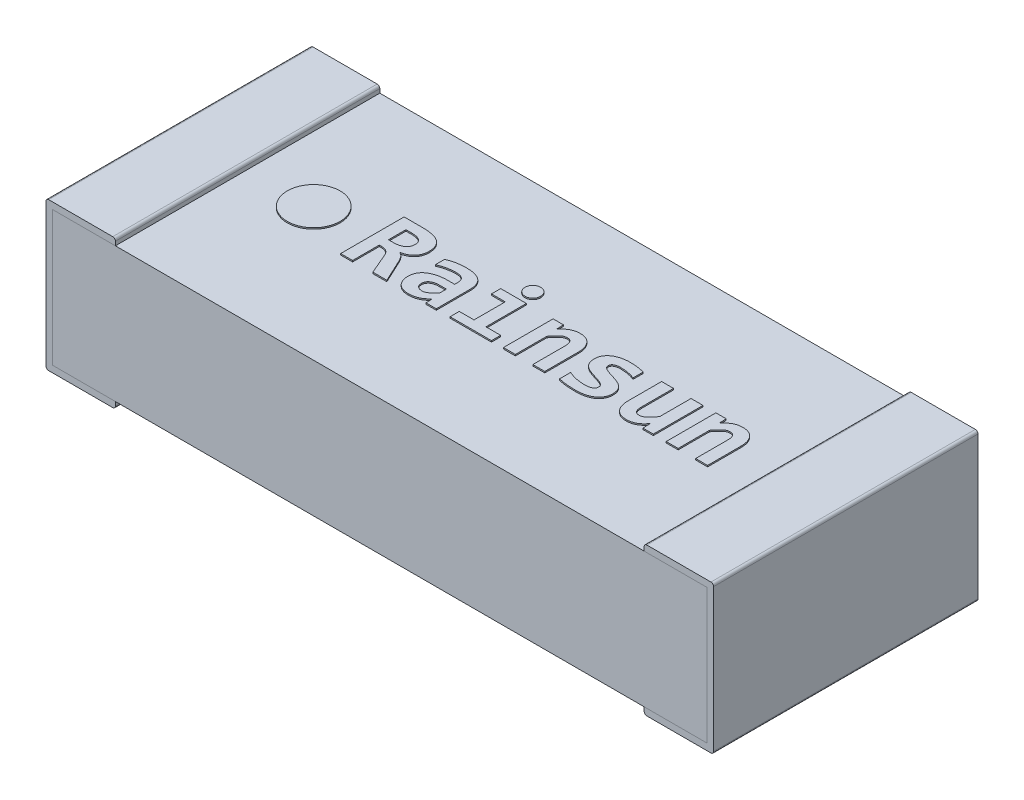
from build123d import *

# Parameters (mm, degrees)
EXTRUDE_THIN1_DEPTH      = 1
EXTRUDE_THIN1_DEPTH_BACK = 1
BOSS_EXTRUDE1_DEPTH      = 1
BOSS_EXTRUDE1_DEPTH_BACK = 1
SKETCH2_W                = 4.95
SKETCH2_H                = 1.02
SKETCH3_R                = 0.2
BOSS_EXTRUDE2_DEPTH      = 0.01
BOSS_EXTRUDE2_2_DEPTH    = 0.01
BOSS_EXTRUDE2_3_DEPTH    = 0.01
BOSS_EXTRUDE2_4_DEPTH    = 0.01
BOSS_EXTRUDE2_5_DEPTH    = 0.01
BOSS_EXTRUDE2_6_DEPTH    = 0.01
BOSS_EXTRUDE2_7_DEPTH    = 0.01
BOSS_EXTRUDE2_8_DEPTH    = 0.01
BOSS_EXTRUDE2_9_DEPTH    = 0.01
FILLET1_R                = 0.02
FILLET2_R                = 0.02


with BuildPart() as part:
    # Sketch1 → Extrude-Thin1 (new, two sides: drawn at the far end of the back side and taken through both)
    with BuildSketch(Plane.XY.offset(-EXTRUDE_THIN1_DEPTH_BACK)):
        Polygon((2, 1.07), (2.475, 1.07), (2.475, 0.05), (2, 0.05), (2, 0), (2.525, 0), (2.525, 1.12), (2, 1.12), align=None)
    extrude(amount=EXTRUDE_THIN1_DEPTH + EXTRUDE_THIN1_DEPTH_BACK)


with BuildPart() as body_2:
    # Mirror1: mirrored copy
    add(part.part.mirror(Plane(origin=(0, 0, 0), x_dir=(0, 0, 1), z_dir=(1, 0, 0))))

    # Fillet2
    fillet2_edges = [body_2.edges().sort_by_distance(p)[0] for p in [
        (-2.525, 0, 0),
        (-2.525, 1.12, 0),
        (-2, 1.12, 0),
        (-2, 0, 0),
    ]]
    fillet(fillet2_edges, radius=FILLET2_R)


with BuildPart() as body_3:
    # Sketch2 → Boss-Extrude1 (new, two sides: drawn at the far end of the back side and taken through both)
    with BuildSketch(Plane.XY.offset(-BOSS_EXTRUDE1_DEPTH_BACK)):
        with Locations((0, 0.56)):
            Rectangle(SKETCH2_W, SKETCH2_H)
    extrude(amount=BOSS_EXTRUDE1_DEPTH + BOSS_EXTRUDE1_DEPTH_BACK)


with BuildPart() as body_4:
    # Sketch3 → Boss-Extrude2 (new body)
    with BuildSketch(Plane(origin=(0, 1.07, 0), x_dir=(1, 0, 0), z_dir=(0, 1, 0))):
        with Locations((-1.5, 0)):
            Circle(SKETCH3_R)
    extrude(amount=BOSS_EXTRUDE2_DEPTH)


with BuildPart() as body_5:
    # Sketch3 → Boss-Extrude2 2 (new body)
    with BuildSketch(Plane(origin=(0, 1.07, 0), x_dir=(1, 0, 0), z_dir=(0, 1, 0))):
        with BuildLine():
            Line((-0.844027182, -0.208611629), (-0.9110924, -0.051981194))
            add(Edge.make_bspline(
                [(-0.9110924, -0.051981194), (-0.912724491, -0.048408124), (-0.915895955, -0.041464965), (-0.92231498, -0.032270437), (-0.929638163, -0.024414484), (-0.93802681, -0.018068753), (-0.947210117, -0.013026992), (-0.957241109, -0.009375934), (-0.968076466, -0.007349202), (-0.975540883, -0.007033659), (-0.979353269, -0.006872498)],
                knots=[0, 0, 0, 0, 1.07937985, 2.097441539, 3.071055259, 4.024539089, 4.97969058, 5.945096662, 6.95047571, 8, 8, 8, 8], degree=3))
            Line((-0.979353269, -0.006872498), (-0.997070661, -0.006872498))
            Line((-0.997070661, -0.006872498), (-0.997070661, -0.208611629))
            Line((-0.997070661, -0.208611629), (-1.087505443, -0.208611629))
            Line((-1.087505443, -0.208611629), (-1.087505443, 0.271388371))
            Line((-1.087505443, 0.271388371), (-0.945114139, 0.271388371))
            add(Edge.make_bspline(
                [(-0.945114139, 0.271388371), (-0.938518721, 0.271294928), (-0.925642888, 0.271112504), (-0.9068017, 0.269982968), (-0.888965799, 0.267748367), (-0.872061074, 0.264897347), (-0.856193594, 0.261028587), (-0.841444195, 0.256092954), (-0.827984555, 0.249846241), (-0.815734388, 0.242538225), (-0.804646038, 0.234194727), (-0.794990984, 0.224505948), (-0.786678676, 0.213647111), (-0.779626238, 0.20160794), (-0.77419529, 0.188202493), (-0.770298097, 0.173453594), (-0.7678709, 0.157301885), (-0.767630237, 0.14603506), (-0.767505443, 0.140192719)],
                knots=[0, 0, 0, 0, 1.254438722, 2.448964256, 3.587437174, 4.671603447, 5.707801299, 6.690588177, 7.624750448, 8.524079809, 9.399245701, 10.256818247, 11.116851234, 11.993805779, 12.902354155, 13.858471343, 14.889524007, 16, 16, 16, 16], degree=3))
            add(Edge.make_bspline(
                [(-0.767505443, 0.140192719), (-0.767613783, 0.135949168), (-0.767824709, 0.127687438), (-0.769350061, 0.115631855), (-0.771951115, 0.104310927), (-0.775549557, 0.093723388), (-0.780040459, 0.083862529), (-0.785353529, 0.074692195), (-0.791617186, 0.066261104), (-0.79867143, 0.05856408), (-0.806446125, 0.051615672), (-0.814759336, 0.04522194), (-0.823760456, 0.039600937), (-0.833362472, 0.034747762), (-0.843360775, 0.030458428), (-0.853821712, 0.027041425), (-0.864627966, 0.024148858), (-0.872023009, 0.022821259), (-0.875766313, 0.022149241)],
                knots=[0, 0, 0, 0, 1.155349972, 2.249340124, 3.302347646, 4.313193118, 5.288908417, 6.248327119, 7.193487508, 8.143168254, 9.086215168, 10.029416886, 10.995709606, 11.970826185, 12.956664107, 13.955010984, 14.964844911, 16, 16, 16, 16], degree=3))
            add(Edge.make_bspline(
                [(-0.875766313, 0.022149241), (-0.872863792, 0.021388251), (-0.866958302, 0.019839936), (-0.858648882, 0.015387682), (-0.850657058, 0.009596146), (-0.843055631, 0.002125517), (-0.835746063, -0.007110378), (-0.828388906, -0.018075842), (-0.821129166, -0.03097671), (-0.816618277, -0.040323584), (-0.814244574, -0.045242063)],
                knots=[0, 0, 0, 0, 0.75991202, 1.546122521, 2.376404305, 3.261596413, 4.243343524, 5.3639781, 6.612881775, 8, 8, 8, 8], degree=3))
            Line((-0.814244574, -0.045242063), (-0.738048922, -0.208611629))
            Line((-0.738048922, -0.208611629), (-0.844027182, -0.208611629))
        make_face()
        with BuildLine():
            add(Edge.make_bspline(
                [(-0.864896748, 0.130410111), (-0.864948738, 0.13316709), (-0.865049739, 0.138523065), (-0.866130627, 0.146259122), (-0.868010843, 0.153388059), (-0.870455141, 0.159912803), (-0.873688298, 0.165857964), (-0.877706405, 0.17114269), (-0.882413792, 0.175875867), (-0.887873959, 0.179931668), (-0.893952459, 0.18351969), (-0.900789425, 0.186551317), (-0.908302451, 0.189183712), (-0.916580804, 0.191179279), (-0.92554313, 0.192823986), (-0.935235431, 0.193982811), (-0.945644261, 0.19478164), (-0.952829902, 0.194837758), (-0.956527182, 0.194866632)],
                knots=[0, 0, 0, 0, 1.03221539, 2.00528173, 2.91708139, 3.789130794, 4.609038712, 5.442315575, 6.267597059, 7.100873922, 7.98300273, 8.906244241, 9.897686097, 10.9608414, 12.092146654, 13.309174969, 14.615470257, 16, 16, 16, 16], degree=3))
            Line((-0.956527182, 0.194866632), (-0.997070661, 0.194866632))
            Line((-0.997070661, 0.194866632), (-0.997070661, 0.062692719))
            Line((-0.997070661, 0.062692719), (-0.959570661, 0.062692719))
            add(Edge.make_bspline(
                [(-0.959570661, 0.062692719), (-0.952745168, 0.062887139), (-0.939667367, 0.063259652), (-0.923838839, 0.065980449), (-0.912285862, 0.069103671), (-0.904529893, 0.072254502), (-0.89730981, 0.075665841), (-0.89075745, 0.079719428), (-0.884837111, 0.08425857), (-0.879730044, 0.089438511), (-0.875193687, 0.094987795), (-0.871474424, 0.101138485), (-0.868564006, 0.107798969), (-0.86632236, 0.114887197), (-0.865164977, 0.122509959), (-0.864987894, 0.127725569), (-0.864896748, 0.130410111)],
                knots=[0, 0, 0, 0, 2.184691281, 4.185918933, 5.126368008, 6.012027286, 6.863184627, 7.681184451, 8.47504028, 9.246354907, 10.005704987, 10.765941227, 11.540044168, 12.329221459, 13.140028664, 14, 14, 14, 14], degree=3))
        make_face(mode=Mode.SUBTRACT)
    extrude(amount=BOSS_EXTRUDE2_2_DEPTH)


with BuildPart() as body_6:
    # Sketch3 → Boss-Extrude2 3 (new body)
    with BuildSketch(Plane(origin=(0, 1.07, 0), x_dir=(1, 0, 0), z_dir=(0, 1, 0))):
        with BuildLine():
            Line((-0.441635878, -0.208611629), (-0.443809791, -0.159155107))
            add(Edge.make_bspline(
                [(-0.443809791, -0.159155107), (-0.447709917, -0.163119123), (-0.455483575, -0.171020125), (-0.467992706, -0.181934175), (-0.481439504, -0.191776329), (-0.496161515, -0.200059481), (-0.512260222, -0.206717955), (-0.52966785, -0.211901404), (-0.548740743, -0.214951572), (-0.561950829, -0.215357423), (-0.568809791, -0.21556815)],
                knots=[0, 0, 0, 0, 0.942751787, 1.87907519, 2.811864331, 3.763701556, 4.73586472, 5.760432521, 6.837168281, 8, 8, 8, 8], degree=3))
            add(Edge.make_bspline(
                [(-0.568809791, -0.21556815), (-0.57337887, -0.215457971), (-0.582289532, -0.215243099), (-0.595215477, -0.213749186), (-0.607306842, -0.21113623), (-0.618527609, -0.207448713), (-0.6288465, -0.2027656), (-0.638329708, -0.197284177), (-0.646917861, -0.19096641), (-0.65473705, -0.183871567), (-0.661536368, -0.175886197), (-0.667651633, -0.167261824), (-0.67257331, -0.157688149), (-0.676883017, -0.147476364), (-0.680080344, -0.136524097), (-0.682348717, -0.12499052), (-0.683814347, -0.112961039), (-0.68395555, -0.104739117), (-0.684027182, -0.10056815)],
                knots=[0, 0, 0, 0, 1.188820374, 2.318449472, 3.379888704, 4.402475042, 5.385577281, 6.32342832, 7.24738733, 8.154894716, 9.063967784, 9.97147517, 10.899274027, 11.85872107, 12.852031674, 13.861540196, 14.915163189, 16, 16, 16, 16], degree=3))
            add(Edge.make_bspline(
                [(-0.684027182, -0.10056815), (-0.683929602, -0.096245089), (-0.683737233, -0.087722692), (-0.681381268, -0.075286898), (-0.678096956, -0.063270458), (-0.673159253, -0.051845821), (-0.666794841, -0.04101833), (-0.65910857, -0.030857148), (-0.649765661, -0.021651163), (-0.63911547, -0.013155708), (-0.626924375, -0.005571348), (-0.61345668, 0.001290715), (-0.598517369, 0.007153849), (-0.582200877, 0.012119147), (-0.564416532, 0.016185085), (-0.545144837, 0.018894166), (-0.524424157, 0.02070483), (-0.510118352, 0.020868815), (-0.502722835, 0.020953589)],
                knots=[0, 0, 0, 0, 0.846334836, 1.668447797, 2.473381772, 3.284808262, 4.099802161, 4.930887555, 5.774685007, 6.664352488, 7.596475241, 8.584410062, 9.623785724, 10.738215398, 11.925463769, 13.196192477, 14.550545786, 16, 16, 16, 16], degree=3))
            Line((-0.502722835, 0.020953589), (-0.454461965, 0.020953589))
            Line((-0.454461965, 0.020953589), (-0.454461965, 0.043018806))
            add(Edge.make_bspline(
                [(-0.454461965, 0.043018806), (-0.454626751, 0.04749412), (-0.454944495, 0.056123539), (-0.458024842, 0.068375239), (-0.463230273, 0.079271331), (-0.46982471, 0.086768163), (-0.476246413, 0.09163378), (-0.481679373, 0.095079269), (-0.487909063, 0.09781367), (-0.49472936, 0.100239178), (-0.502274599, 0.102250114), (-0.51066674, 0.103422541), (-0.519838328, 0.104391165), (-0.526234194, 0.104417902), (-0.529570661, 0.10443185)],
                knots=[0, 0, 0, 0, 1.447721202, 2.79153421, 4.061974913, 5.326381525, 5.97912129, 6.669712629, 7.405140625, 8.177401359, 9.014479125, 9.929270305, 10.919783635, 12, 12, 12, 12], degree=3))
            add(Edge.make_bspline(
                [(-0.529570661, 0.10443185), (-0.535008804, 0.104357696), (-0.545903537, 0.104209138), (-0.562155131, 0.102710789), (-0.578353121, 0.100473913), (-0.599654915, 0.096042767), (-0.626005571, 0.089001452), (-0.646133255, 0.080738753), (-0.656201095, 0.076605763)],
                knots=[0, 0, 0, 0, 0.749590158, 1.5017228, 2.248461115, 3.002830009, 4.500819683, 6, 6, 6, 6], degree=3))
            Line((-0.656201095, 0.076605763), (-0.656201095, 0.14617098))
            add(Edge.make_bspline(
                [(-0.656201095, 0.14617098), (-0.651585603, 0.148148122), (-0.642133848, 0.152196976), (-0.627139904, 0.157333599), (-0.611214265, 0.162162376), (-0.594289086, 0.166214642), (-0.576722777, 0.169725424), (-0.558652573, 0.172238357), (-0.540244903, 0.173630614), (-0.527869964, 0.173874304), (-0.521635878, 0.173997067)],
                knots=[0, 0, 0, 0, 0.870643359, 1.78293153, 2.747244943, 3.756289436, 4.800212086, 5.853400504, 6.918614031, 8, 8, 8, 8], degree=3))
            add(Edge.make_bspline(
                [(-0.521635878, 0.173997067), (-0.514967081, 0.173879689), (-0.502121187, 0.173653587), (-0.483560782, 0.172298581), (-0.466488551, 0.169820773), (-0.450820732, 0.166352106), (-0.43654095, 0.16194037), (-0.423550941, 0.156488243), (-0.411923425, 0.149988597), (-0.401555581, 0.142517831), (-0.392461157, 0.134120628), (-0.384628485, 0.124678772), (-0.378221666, 0.114129335), (-0.372969312, 0.102635716), (-0.368987227, 0.090140704), (-0.36603811, 0.076684523), (-0.364299576, 0.062231233), (-0.364119536, 0.052262705), (-0.364027182, 0.047149241)],
                knots=[0, 0, 0, 0, 1.377759711, 2.653935252, 3.841633143, 4.938469235, 5.965914915, 6.92517161, 7.843396777, 8.711792949, 9.559226208, 10.39396998, 11.237393933, 12.101553923, 12.998669062, 13.941252007, 14.943942973, 16, 16, 16, 16], degree=3))
            Line((-0.364027182, 0.047149241), (-0.364027182, -0.208611629))
            Line((-0.364027182, -0.208611629), (-0.441635878, -0.208611629))
        make_face()
        with BuildLine():
            Line((-0.454461965, -0.041655107), (-0.506853269, -0.041655107))
            add(Edge.make_bspline(
                [(-0.506853269, -0.041655107), (-0.510331638, -0.041739255), (-0.517043124, -0.04190162), (-0.526729811, -0.042531769), (-0.535568555, -0.044146716), (-0.543608134, -0.046048084), (-0.550905862, -0.048435928), (-0.557389618, -0.051382079), (-0.563243656, -0.05464593), (-0.569939281, -0.059461878), (-0.576769101, -0.066589127), (-0.582666466, -0.076396134), (-0.586025409, -0.08723894), (-0.586430458, -0.094712639), (-0.586635878, -0.098502933)],
                knots=[0, 0, 0, 0, 1.1346769, 2.18935077, 3.160455313, 4.060166297, 4.882052532, 5.659342063, 6.378819937, 7.064121245, 8.342468752, 9.566207994, 10.765699828, 12, 12, 12, 12], degree=3))
            add(Edge.make_bspline(
                [(-0.586635878, -0.098502933), (-0.586483805, -0.102141754), (-0.586193463, -0.109089121), (-0.583594423, -0.118889623), (-0.579036312, -0.127240371), (-0.57278458, -0.134178096), (-0.564949069, -0.139482397), (-0.555831879, -0.143330989), (-0.545443195, -0.145623723), (-0.538097296, -0.145872471), (-0.534244574, -0.146002933)],
                knots=[0, 0, 0, 0, 1.086697673, 2.074761695, 3.000659932, 3.905665256, 4.840141479, 5.805924735, 6.849267962, 8, 8, 8, 8], degree=3))
            add(Edge.make_bspline(
                [(-0.534244574, -0.146002933), (-0.531218551, -0.145829094), (-0.524987283, -0.145471122), (-0.515667567, -0.14261902), (-0.506100472, -0.138395598), (-0.496524759, -0.132103229), (-0.486667196, -0.12427944), (-0.476207271, -0.115149988), (-0.465337373, -0.104464507), (-0.45819142, -0.096619146), (-0.454461965, -0.092524672)],
                knots=[0, 0, 0, 0, 0.735319699, 1.514190145, 2.354950119, 3.274773688, 4.292602642, 5.417493931, 6.652196731, 8, 8, 8, 8], degree=3))
            Line((-0.454461965, -0.092524672), (-0.454461965, -0.041655107))
        make_face(mode=Mode.SUBTRACT)
    extrude(amount=BOSS_EXTRUDE2_3_DEPTH)


with BuildPart() as body_7:
    # Sketch3 → Boss-Extrude2 4 (new body)
    with BuildSketch(Plane(origin=(0, 1.07, 0), x_dir=(1, 0, 0), z_dir=(0, 1, 0))):
        with BuildLine():
            add(Edge.make_bspline(
                [(-0.050983704, 0.267692719), (-0.051171373, 0.263715714), (-0.051541823, 0.255865291), (-0.055127323, 0.244677359), (-0.060389838, 0.234467659), (-0.06765613, 0.225732885), (-0.076446194, 0.218526987), (-0.086490256, 0.212975645), (-0.097861985, 0.209455409), (-0.105813413, 0.209008949), (-0.109896748, 0.208779676)],
                knots=[0, 0, 0, 0, 1.027278296, 2.027799504, 3.01435772, 3.987703108, 4.947837318, 5.943283625, 6.943804833, 8, 8, 8, 8], degree=3))
            add(Edge.make_bspline(
                [(-0.109896748, 0.208779676), (-0.113975348, 0.209023347), (-0.12202171, 0.209504068), (-0.133556147, 0.21288676), (-0.143679679, 0.218609168), (-0.152681345, 0.225616256), (-0.159817978, 0.234517424), (-0.165109423, 0.244669374), (-0.168684259, 0.255867361), (-0.169056166, 0.26371641), (-0.169244574, 0.267692719)],
                knots=[0, 0, 0, 0, 1.05151676, 2.074458121, 3.065495108, 4.035879517, 4.99899435, 5.981182615, 6.977272023, 8, 8, 8, 8], degree=3))
            add(Edge.make_bspline(
                [(-0.169244574, 0.267692719), (-0.169059161, 0.271705685), (-0.168694793, 0.279591852), (-0.165111803, 0.290824987), (-0.159796078, 0.301001098), (-0.152647166, 0.309959392), (-0.143786134, 0.317260448), (-0.133493764, 0.322757301), (-0.122049296, 0.326361044), (-0.113981119, 0.326812171), (-0.109896748, 0.327040545)],
                knots=[0, 0, 0, 0, 1.028612134, 2.021399971, 3.000332741, 3.967500779, 4.946433548, 5.929741804, 6.951968527, 8, 8, 8, 8], degree=3))
            add(Edge.make_bspline(
                [(-0.109896748, 0.327040545), (-0.105807412, 0.326826904), (-0.097833575, 0.326410324), (-0.086552849, 0.322669261), (-0.076338645, 0.317341495), (-0.067692994, 0.309842499), (-0.060411331, 0.301050551), (-0.055125009, 0.290817073), (-0.051531248, 0.279593927), (-0.051168363, 0.271706384), (-0.050983704, 0.267692719)],
                knots=[0, 0, 0, 0, 1.052651845, 2.052576496, 3.040219784, 4.00912662, 4.986439932, 5.969688445, 6.966853106, 8, 8, 8, 8], degree=3))
        make_face()
    extrude(amount=BOSS_EXTRUDE2_4_DEPTH)


with BuildPart() as body_8:
    # Sketch3 → Boss-Extrude2 5 (new body)
    with BuildSketch(Plane(origin=(0, 1.07, 0), x_dir=(1, 0, 0), z_dir=(0, 1, 0))):
        Polygon((-0.148375009, 0.097475328), (-0.252722835, 0.097475328), (-0.252722835, 0.167040545), (-0.057940226, 0.167040545), (-0.057940226, -0.139046411), (0.053364122, -0.139046411), (0.053364122, -0.208611629), (-0.259679356, -0.208611629), (-0.259679356, -0.139046411), (-0.148375009, -0.139046411), align=None)
    extrude(amount=BOSS_EXTRUDE2_5_DEPTH)


with BuildPart() as body_9:
    # Sketch3 → Boss-Extrude2 6 (new body)
    with BuildSketch(Plane(origin=(0, 1.07, 0), x_dir=(1, 0, 0), z_dir=(0, 1, 0))):
        with BuildLine():
            Line((0.3664076, -0.208611629), (0.3664076, 0.035844893))
            add(Edge.make_bspline(
                [(0.3664076, 0.035844893), (0.366259792, 0.040670573), (0.365982627, 0.049719553), (0.364012298, 0.062413279), (0.360478821, 0.073161917), (0.3555561, 0.082126802), (0.348954376, 0.089064561), (0.340942465, 0.094100907), (0.331413316, 0.096974791), (0.324652203, 0.097302342), (0.321081513, 0.097475328)],
                knots=[0, 0, 0, 0, 1.330337845, 2.494612452, 3.527515131, 4.435664575, 5.29056087, 6.138661007, 7.016986611, 8, 8, 8, 8], degree=3))
            add(Edge.make_bspline(
                [(0.321081513, 0.097475328), (0.317325831, 0.097226678), (0.309774256, 0.096726714), (0.298578937, 0.093153556), (0.287815749, 0.087144608), (0.277291584, 0.078904816), (0.267022785, 0.068627196), (0.256123049, 0.057015669), (0.245276719, 0.043445325), (0.23801259, 0.033798231), (0.234233687, 0.028779676)],
                knots=[0, 0, 0, 0, 0.785464114, 1.579338109, 2.434441881, 3.353550729, 4.367060634, 5.472426257, 6.685120424, 8, 8, 8, 8], degree=3))
            Line((0.234233687, 0.028779676), (0.234233687, -0.208611629))
            Line((0.234233687, -0.208611629), (0.143798905, -0.208611629))
            Line((0.143798905, -0.208611629), (0.143798905, 0.167040545))
            Line((0.143798905, 0.167040545), (0.22216847, 0.167040545))
            Line((0.22216847, 0.167040545), (0.224342383, 0.111605763))
            add(Edge.make_bspline(
                [(0.224342383, 0.111605763), (0.228164433, 0.116146657), (0.235682864, 0.125079141), (0.247735358, 0.137456067), (0.260592735, 0.148346185), (0.27449802, 0.157477497), (0.289528043, 0.164682378), (0.305741664, 0.170114231), (0.323589883, 0.173465484), (0.336065942, 0.173814295), (0.342603252, 0.173997067)],
                knots=[0, 0, 0, 0, 1.024448882, 2.015214114, 2.978651595, 3.927625391, 4.878802298, 5.848009221, 6.87238172, 8, 8, 8, 8], degree=3))
            add(Edge.make_bspline(
                [(0.342603252, 0.173997067), (0.347248956, 0.17392269), (0.356254236, 0.173778517), (0.369270491, 0.171810559), (0.38140735, 0.168986963), (0.392552423, 0.164763594), (0.402882997, 0.159681927), (0.412222361, 0.15345182), (0.420742284, 0.146290939), (0.428330122, 0.138120655), (0.435055657, 0.129054346), (0.441065397, 0.119183453), (0.445844092, 0.108280855), (0.449889287, 0.096614145), (0.453018276, 0.084172495), (0.455303383, 0.071024588), (0.456601789, 0.057139365), (0.456760869, 0.04765917), (0.456842383, 0.042801415)],
                knots=[0, 0, 0, 0, 1.128292418, 2.187093889, 3.193297493, 4.152042544, 5.077728068, 5.986496946, 6.874059951, 7.777692081, 8.690209529, 9.614679004, 10.580558963, 11.577778426, 12.613878209, 13.695586306, 14.819193276, 16, 16, 16, 16], degree=3))
            Line((0.456842383, 0.042801415), (0.456842383, -0.208611629))
            Line((0.456842383, -0.208611629), (0.3664076, -0.208611629))
        make_face()
    extrude(amount=BOSS_EXTRUDE2_6_DEPTH)


with BuildPart() as body_10:
    # Sketch3 → Boss-Extrude2 7 (new body)
    with BuildSketch(Plane(origin=(0, 1.07, 0), x_dir=(1, 0, 0), z_dir=(0, 1, 0))):
        with BuildLine():
            add(Edge.make_bspline(
                [(0.860320644, -0.097307281), (0.860167168, -0.102464036), (0.859871038, -0.112413943), (0.857204729, -0.126802435), (0.852774731, -0.139981812), (0.846599899, -0.152004559), (0.838910538, -0.162738896), (0.830140968, -0.172529919), (0.820214718, -0.181250677), (0.809147658, -0.188848519), (0.797209725, -0.195479917), (0.784359205, -0.201007617), (0.770812025, -0.205684388), (0.756580405, -0.209314203), (0.741950852, -0.212141202), (0.727026843, -0.214056698), (0.711935709, -0.215296743), (0.701808547, -0.215477547), (0.696733687, -0.21556815)],
                knots=[0, 0, 0, 0, 1.09100478, 2.105082402, 3.085106755, 4.025136879, 4.955223976, 5.873211658, 6.802665871, 7.745321433, 8.710187751, 9.689250942, 10.703270536, 11.74146176, 12.796073428, 13.856028036, 14.925626204, 16, 16, 16, 16], degree=3))
            add(Edge.make_bspline(
                [(0.696733687, -0.21556815), (0.690102935, -0.215524524), (0.677164164, -0.215439394), (0.658275372, -0.214834056), (0.640378615, -0.213572878), (0.618118571, -0.211633897), (0.591702623, -0.2081043), (0.571203697, -0.203771587), (0.561190209, -0.201655107)],
                knots=[0, 0, 0, 0, 0.874092444, 1.705641045, 2.49069391, 3.2387718, 4.651171983, 6, 6, 6, 6], degree=3))
            Line((0.561190209, -0.201655107), (0.561190209, -0.118176846))
            add(Edge.make_bspline(
                [(0.561190209, -0.118176846), (0.566850865, -0.120533303), (0.578056265, -0.125197965), (0.595178901, -0.130835221), (0.612170571, -0.135866556), (0.629149964, -0.139593635), (0.645888069, -0.142380323), (0.662162155, -0.144489216), (0.677982981, -0.145711948), (0.688362193, -0.145906927), (0.693472818, -0.146002933)],
                knots=[0, 0, 0, 0, 1.081001824, 2.139868395, 3.177367493, 4.2052384, 5.203238289, 6.169410181, 7.098635214, 8, 8, 8, 8], degree=3))
            add(Edge.make_bspline(
                [(0.693472818, -0.146002933), (0.698915514, -0.145904263), (0.709157395, -0.145718591), (0.723390069, -0.1436913), (0.735542273, -0.140425092), (0.745447559, -0.135641565), (0.753287009, -0.129783776), (0.758823682, -0.122810206), (0.76233756, -0.114967688), (0.762730811, -0.109371561), (0.762929339, -0.106546411)],
                knots=[0, 0, 0, 0, 1.469547571, 2.76534487, 3.874676932, 4.855352958, 5.720794042, 6.494385122, 7.239905003, 8, 8, 8, 8], degree=3))
            add(Edge.make_bspline(
                [(0.762929339, -0.106546411), (0.762791428, -0.103801666), (0.76252211, -0.098441636), (0.759434899, -0.090680639), (0.753854483, -0.083466166), (0.746886769, -0.078372398), (0.739890695, -0.074275253), (0.733341614, -0.071031771), (0.725775945, -0.067785922), (0.717155108, -0.064394182), (0.707258938, -0.060950859), (0.696103576, -0.057092362), (0.683463072, -0.053232254), (0.674562557, -0.050630743), (0.669885861, -0.049263802)],
                knots=[0, 0, 0, 0, 0.84533218, 1.65079333, 2.538454206, 3.632493948, 4.295634353, 5.047457499, 5.890706844, 6.841828332, 7.912366296, 9.131567036, 10.492807614, 12, 12, 12, 12], degree=3))
            add(Edge.make_bspline(
                [(0.669885861, -0.049263802), (0.665453528, -0.04796115), (0.656865135, -0.045437041), (0.644491514, -0.041116743), (0.632932321, -0.036735718), (0.622179847, -0.032083516), (0.612346669, -0.026942819), (0.603360881, -0.021445065), (0.595187462, -0.015558587), (0.588018334, -0.009109196), (0.581585258, -0.002231402), (0.576221417, 0.005281143), (0.571548653, 0.013226537), (0.567730642, 0.0217445), (0.564771508, 0.030965839), (0.562783845, 0.040887171), (0.561403599, 0.051531233), (0.561263034, 0.058883569), (0.561190209, 0.062692719)],
                knots=[0, 0, 0, 0, 1.298059187, 2.515208454, 3.681910853, 4.771561692, 5.80536043, 6.797244313, 7.72998402, 8.631353089, 9.503256889, 10.370869679, 11.219576383, 12.090052196, 12.98842591, 13.934956945, 14.930127727, 16, 16, 16, 16], degree=3))
            add(Edge.make_bspline(
                [(0.561190209, 0.062692719), (0.561313322, 0.066433511), (0.561558852, 0.073893949), (0.563603651, 0.084866537), (0.566749557, 0.095531338), (0.57123199, 0.105797234), (0.577042533, 0.115576981), (0.583973018, 0.124900491), (0.592391148, 0.133375133), (0.601877918, 0.14137104), (0.612647909, 0.148644901), (0.624728009, 0.155063993), (0.638002391, 0.16069459), (0.652532219, 0.165501121), (0.668355406, 0.169254924), (0.685415769, 0.172095643), (0.703767948, 0.173702226), (0.716404502, 0.173896668), (0.722929339, 0.173997067)],
                knots=[0, 0, 0, 0, 0.81844251, 1.632258835, 2.435372986, 3.248879964, 4.077409159, 4.921438882, 5.785327376, 6.686227262, 7.634496058, 8.624673457, 9.676692434, 10.787963939, 11.971224401, 13.233604305, 14.571581922, 16, 16, 16, 16], degree=3))
            add(Edge.make_bspline(
                [(0.722929339, 0.173997067), (0.72858322, 0.173979533), (0.739608428, 0.17394534), (0.755589231, 0.172985808), (0.770620783, 0.171798305), (0.788747417, 0.169125818), (0.809385953, 0.165507403), (0.825189295, 0.161815866), (0.832603252, 0.160084024)],
                knots=[0, 0, 0, 0, 0.917866331, 1.789862171, 2.598956885, 3.365252049, 4.763938053, 6, 6, 6, 6], degree=3))
            Line((0.832603252, 0.160084024), (0.832603252, 0.083562285))
            add(Edge.make_bspline(
                [(0.832603252, 0.083562285), (0.827436964, 0.085382785), (0.817350475, 0.088937069), (0.802297847, 0.093395852), (0.787723103, 0.097028274), (0.769007697, 0.100548257), (0.746077925, 0.103737423), (0.727760233, 0.104201876), (0.718690209, 0.10443185)],
                knots=[0, 0, 0, 0, 0.846930216, 1.653518287, 2.426723928, 3.168432911, 4.597946698, 6, 6, 6, 6], degree=3))
            add(Edge.make_bspline(
                [(0.718690209, 0.10443185), (0.714371089, 0.104352165), (0.706164536, 0.104200759), (0.69450327, 0.102406107), (0.684130341, 0.099671538), (0.675191503, 0.09581062), (0.667790752, 0.091007793), (0.66254497, 0.084960442), (0.659024461, 0.078034428), (0.658731309, 0.072988492), (0.658581513, 0.070410111)],
                knots=[0, 0, 0, 0, 1.353575655, 2.571864774, 3.691201644, 4.708948433, 5.616762544, 6.430341097, 7.197932669, 8, 8, 8, 8], degree=3))
            add(Edge.make_bspline(
                [(0.658581513, 0.070410111), (0.658760024, 0.06771684), (0.659103113, 0.062540497), (0.661498079, 0.054882986), (0.667020503, 0.048132456), (0.673450764, 0.043055884), (0.680185439, 0.039138773), (0.686473577, 0.036011539), (0.693602034, 0.032601487), (0.70183175, 0.029275745), (0.711186467, 0.025701927), (0.721900312, 0.022248199), (0.733921852, 0.018335187), (0.742448934, 0.01592289), (0.746951078, 0.014649241)],
                knots=[0, 0, 0, 0, 0.870697754, 1.673441418, 2.541463244, 3.639458581, 4.305527314, 5.053652362, 5.906646156, 6.855989708, 7.918451188, 9.139200481, 10.489549865, 12, 12, 12, 12], degree=3))
            add(Edge.make_bspline(
                [(0.746951078, 0.014649241), (0.752073597, 0.013135058), (0.761943772, 0.010217497), (0.775960534, 0.005305015), (0.788716744, 0.000289876), (0.800327278, -0.00474492), (0.810666766, -0.010238874), (0.820067003, -0.015861403), (0.828258372, -0.022026236), (0.835462335, -0.02854037), (0.841704306, -0.035384603), (0.846965874, -0.042711946), (0.851260213, -0.050527939), (0.85459364, -0.058834872), (0.857250995, -0.067632294), (0.85905501, -0.076992288), (0.860174025, -0.086953689), (0.86027083, -0.093789648), (0.860320644, -0.097307281)],
                knots=[0, 0, 0, 0, 1.468847332, 2.830205578, 4.082896833, 5.238283093, 6.307996066, 7.300882441, 8.247490943, 9.122195316, 9.968750424, 10.790004622, 11.59717443, 12.415036503, 13.247279274, 14.120790984, 15.033000747, 16, 16, 16, 16], degree=3))
        make_face()
    extrude(amount=BOSS_EXTRUDE2_7_DEPTH)


with BuildPart() as body_11:
    # Sketch3 → Boss-Extrude2 8 (new body)
    with BuildSketch(Plane(origin=(0, 1.07, 0), x_dir=(1, 0, 0), z_dir=(0, 1, 0))):
        with BuildLine():
            Line((1.055103252, 0.167040545), (1.055103252, -0.077089889))
            add(Edge.make_bspline(
                [(1.055103252, -0.077089889), (1.055253916, -0.081878681), (1.055537433, -0.090890152), (1.057487282, -0.103554837), (1.061087211, -0.114341919), (1.065919835, -0.123449418), (1.072521302, -0.130530635), (1.080646207, -0.135583948), (1.090265788, -0.138561997), (1.097146714, -0.13887976), (1.100755426, -0.139046411)],
                knots=[0, 0, 0, 0, 1.31270137, 2.470220042, 3.497129097, 4.417319378, 5.2744763, 6.117655166, 7.012801186, 8, 8, 8, 8], degree=3))
            add(Edge.make_bspline(
                [(1.100755426, -0.139046411), (1.104480109, -0.138810983), (1.111982184, -0.138336794), (1.122985432, -0.134551248), (1.133774964, -0.128761447), (1.144067793, -0.120299664), (1.154467247, -0.110070414), (1.165277685, -0.098303021), (1.176278555, -0.084800391), (1.183507705, -0.075160071), (1.187277165, -0.070133368)],
                knots=[0, 0, 0, 0, 0.779254789, 1.569537317, 2.415803147, 3.33516661, 4.350409456, 5.47398431, 6.682872188, 8, 8, 8, 8], degree=3))
            Line((1.187277165, -0.070133368), (1.187277165, 0.167040545))
            Line((1.187277165, 0.167040545), (1.277711948, 0.167040545))
            Line((1.277711948, 0.167040545), (1.277711948, -0.208611629))
            Line((1.277711948, -0.208611629), (1.199342383, -0.208611629))
            Line((1.199342383, -0.208611629), (1.19716847, -0.153176846))
            add(Edge.make_bspline(
                [(1.19716847, -0.153176846), (1.193258646, -0.157668136), (1.185580523, -0.166488142), (1.173618571, -0.17886654), (1.160888734, -0.189687053), (1.147220039, -0.198864367), (1.132231725, -0.206057173), (1.115993056, -0.211572214), (1.098147285, -0.215045905), (1.085699505, -0.215389615), (1.079233687, -0.21556815)],
                knots=[0, 0, 0, 0, 1.030992754, 2.024666126, 2.977293315, 3.918575094, 4.866896227, 5.846891158, 6.88159887, 8, 8, 8, 8], degree=3))
            add(Edge.make_bspline(
                [(1.079233687, -0.21556815), (1.074623948, -0.215493026), (1.065618465, -0.215346266), (1.052616641, -0.213360655), (1.040387359, -0.210672351), (1.029152197, -0.206457373), (1.018782349, -0.20126726), (1.009343132, -0.194966416), (1.000707357, -0.187819952), (0.993073088, -0.179609385), (0.986396252, -0.170450341), (0.980533145, -0.160490289), (0.97562772, -0.149616133), (0.971640403, -0.137962521), (0.96844584, -0.125540227), (0.966392666, -0.11235802), (0.964859356, -0.098502336), (0.964733127, -0.089014803), (0.96466847, -0.084155107)],
                knots=[0, 0, 0, 0, 1.116811866, 2.181778732, 3.18353378, 4.148223296, 5.083490636, 5.990084579, 6.894632225, 7.796101715, 8.701204023, 9.638574155, 10.594136258, 11.5889691, 12.622589212, 13.700240707, 14.822019272, 16, 16, 16, 16], degree=3))
            Line((0.96466847, -0.084155107), (0.96466847, 0.167040545))
            Line((0.96466847, 0.167040545), (1.055103252, 0.167040545))
        make_face()
    extrude(amount=BOSS_EXTRUDE2_8_DEPTH)


with BuildPart() as body_12:
    # Sketch3 → Boss-Extrude2 9 (new body)
    with BuildSketch(Plane(origin=(0, 1.07, 0), x_dir=(1, 0, 0), z_dir=(0, 1, 0))):
        with BuildLine():
            Line((1.597711948, -0.208611629), (1.597711948, 0.035844893))
            add(Edge.make_bspline(
                [(1.597711948, 0.035844893), (1.59756414, 0.040670573), (1.597286975, 0.049719553), (1.595316646, 0.062413279), (1.591783169, 0.073161917), (1.586860448, 0.082126802), (1.580258724, 0.089064561), (1.572246813, 0.094100907), (1.562717664, 0.096974791), (1.555956551, 0.097302342), (1.552385861, 0.097475328)],
                knots=[0, 0, 0, 0, 1.330337845, 2.494612452, 3.527515131, 4.435664575, 5.29056087, 6.138661007, 7.016986611, 8, 8, 8, 8], degree=3))
            add(Edge.make_bspline(
                [(1.552385861, 0.097475328), (1.548630179, 0.097226678), (1.541078603, 0.096726714), (1.529883285, 0.093153556), (1.519120097, 0.087144608), (1.508595932, 0.078904816), (1.498327133, 0.068627196), (1.487427397, 0.057015669), (1.476581067, 0.043445325), (1.469316938, 0.033798231), (1.465538035, 0.028779676)],
                knots=[0, 0, 0, 0, 0.785464114, 1.579338109, 2.434441881, 3.353550729, 4.367060634, 5.472426257, 6.685120424, 8, 8, 8, 8], degree=3))
            Line((1.465538035, 0.028779676), (1.465538035, -0.208611629))
            Line((1.465538035, -0.208611629), (1.375103252, -0.208611629))
            Line((1.375103252, -0.208611629), (1.375103252, 0.167040545))
            Line((1.375103252, 0.167040545), (1.453472818, 0.167040545))
            Line((1.453472818, 0.167040545), (1.455646731, 0.111605763))
            add(Edge.make_bspline(
                [(1.455646731, 0.111605763), (1.45946878, 0.116146657), (1.466987212, 0.125079141), (1.479039706, 0.137456067), (1.491897083, 0.148346185), (1.505802368, 0.157477497), (1.520832391, 0.164682378), (1.537046011, 0.170114231), (1.55489423, 0.173465484), (1.56737029, 0.173814295), (1.5739076, 0.173997067)],
                knots=[0, 0, 0, 0, 1.024448882, 2.015214114, 2.978651595, 3.927625391, 4.878802298, 5.848009221, 6.87238172, 8, 8, 8, 8], degree=3))
            add(Edge.make_bspline(
                [(1.5739076, 0.173997067), (1.578553304, 0.17392269), (1.587558584, 0.173778517), (1.600574839, 0.171810559), (1.612711698, 0.168986963), (1.623856771, 0.164763594), (1.634187344, 0.159681927), (1.643526709, 0.15345182), (1.652046632, 0.146290939), (1.659634469, 0.138120655), (1.666360005, 0.129054346), (1.672369745, 0.119183453), (1.67714844, 0.108280855), (1.681193635, 0.096614145), (1.684322624, 0.084172495), (1.686607731, 0.071024588), (1.687906137, 0.057139365), (1.688065217, 0.04765917), (1.688146731, 0.042801415)],
                knots=[0, 0, 0, 0, 1.128292418, 2.187093889, 3.193297493, 4.152042544, 5.077728068, 5.986496946, 6.874059951, 7.777692081, 8.690209529, 9.614679004, 10.580558963, 11.577778426, 12.613878209, 13.695586306, 14.819193276, 16, 16, 16, 16], degree=3))
            Line((1.688146731, 0.042801415), (1.688146731, -0.208611629))
            Line((1.688146731, -0.208611629), (1.597711948, -0.208611629))
        make_face()
    extrude(amount=BOSS_EXTRUDE2_9_DEPTH)


with BuildPart() as part_1:
    add(part.part)

    # Fillet1
    fillet1_edges = [part_1.edges().sort_by_distance(p)[0] for p in [
        (2.525, 0, 0),
        (2.525, 1.12, 0),
        (2, 0, 0),
        (2, 1.12, 0),
    ]]
    fillet(fillet1_edges, radius=FILLET1_R)


solid = Compound([body_2.part, body_3.part, body_4.part, body_5.part, body_6.part, body_7.part, body_8.part, body_9.part, body_10.part, body_11.part, body_12.part, part_1.part])
